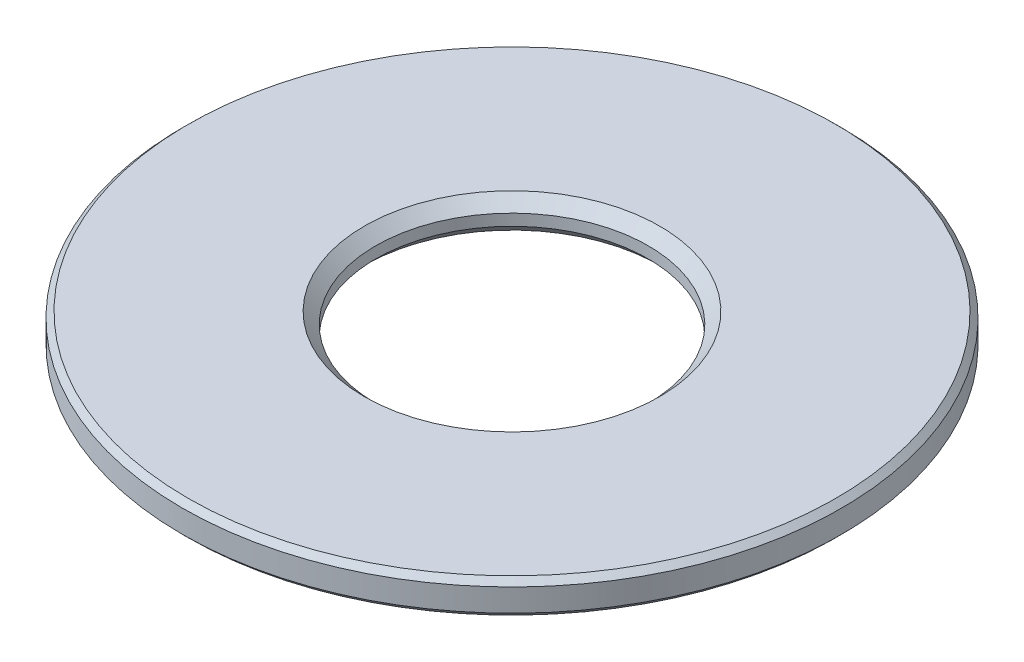
from build123d import *

# Parameters (mm, degrees)
SKETCH1_R          = 29
EXTRUDE1_DEPTH     = 3
SKETCH2_R          = 12
CUT_EXTRUDE1_DEPTH = 4
CHAMFER1_SIZE      = 0.5
CHAMFER2_SIZE      = 1


with BuildPart() as part:
    # Sketch1 → Extrude1 (new body)
    with BuildSketch(Plane(origin=(0, 0, 0), x_dir=(1, 0, 0), z_dir=(0, 1, 0))):
        Circle(SKETCH1_R)
    extrude(amount=EXTRUDE1_DEPTH)

    # Sketch2 → Cut-Extrude1 (cut, through all)
    with BuildSketch(Plane(origin=(0, 3, 0), x_dir=(-1, 0, 0), z_dir=(0, 1, 0))):
        Circle(SKETCH2_R)
    extrude(amount=-CUT_EXTRUDE1_DEPTH, mode=Mode.SUBTRACT)

    # Chamfer1
    chamfer1_edges = [part.edges().sort_by_distance(p)[0] for p in [
        (-29, 0, 0),
        (-29, 3, 0),
    ]]
    chamfer(chamfer1_edges, length=CHAMFER1_SIZE)

    # Chamfer2
    chamfer2_edges = [part.edges().sort_by_distance(p)[0] for p in [
        (12, 0, 0),
        (12, 3, 0),
    ]]
    chamfer(chamfer2_edges, length=CHAMFER2_SIZE)


solid = part.part
